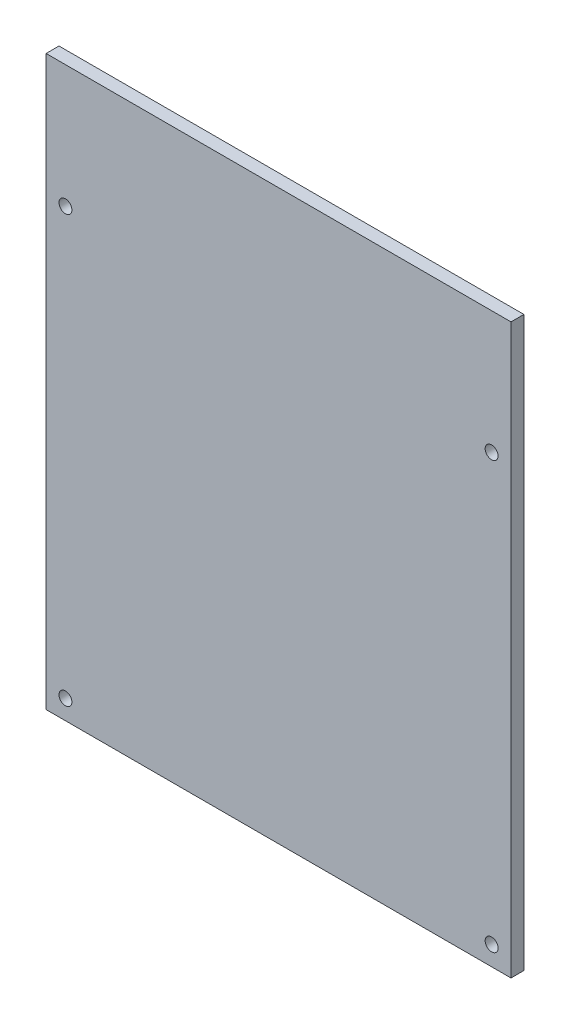
from build123d import *

# Parameters (mm, degrees)
SKETCH1_W           = 457.2
SKETCH1_H           = 558.8
SKETCH1_R           = 6.35
BOSS_EXTRUDE1_DEPTH = 12.7


with BuildPart() as part:
    # Sketch1 → Boss-Extrude1 (new body)
    with BuildSketch(Plane.XY):
        with Locations((15.460869565, -66.813043478)):
            Rectangle(SKETCH1_W, SKETCH1_H)
        with Locations((-194.089130435, 91.936956522)):
            Circle(SKETCH1_R, mode=Mode.SUBTRACT)
        with Locations((225.010869565, 91.936956522)):
            Circle(SKETCH1_R, mode=Mode.SUBTRACT)
        with Locations((225.010869565, -327.163043478)):
            Circle(SKETCH1_R, mode=Mode.SUBTRACT)
        with Locations((-194.089130435, -327.163043478)):
            Circle(SKETCH1_R, mode=Mode.SUBTRACT)
    extrude(amount=BOSS_EXTRUDE1_DEPTH)


solid = part.part
